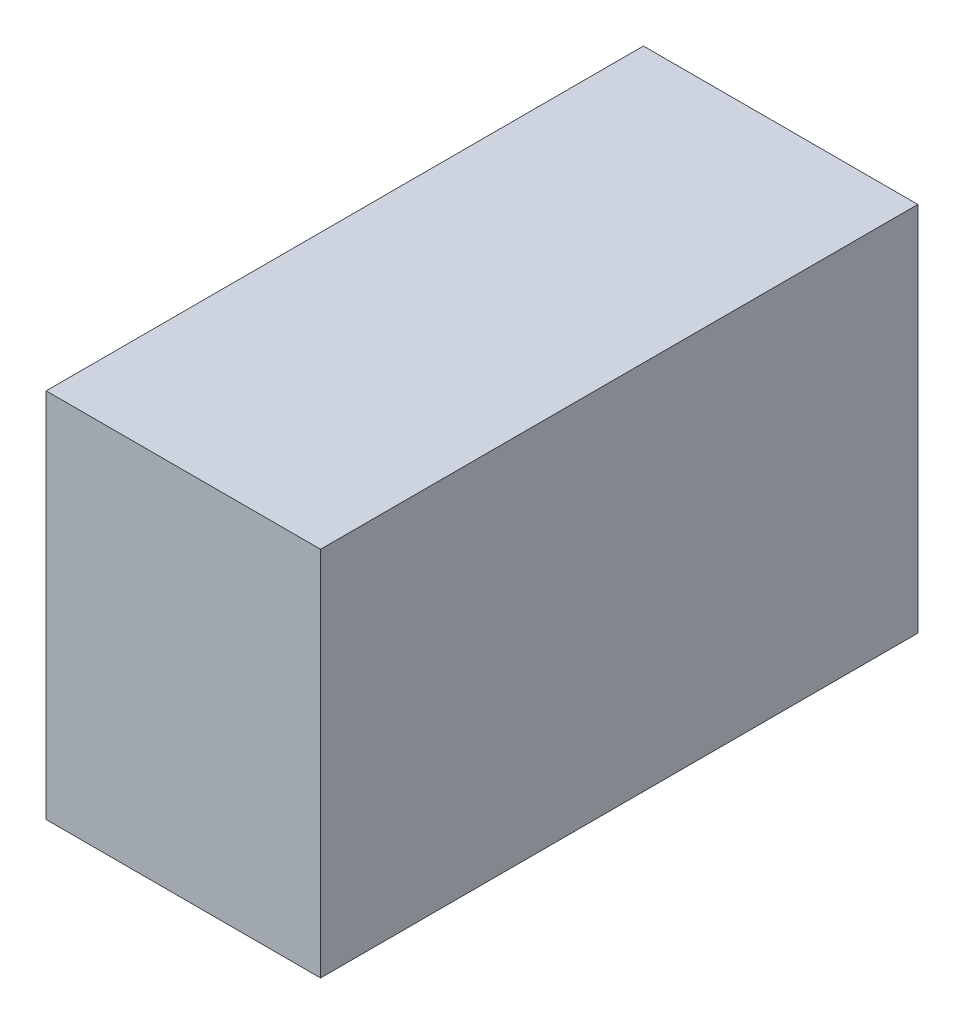
from build123d import *

# Parameters (mm, degrees)
SKETCH2_W           = 34
SKETCH2_H           = 74
BOSS_EXTRUDE1_DEPTH = 46


with BuildPart() as part:
    # Sketch2 → Boss-Extrude1 (new body)
    with BuildSketch(Plane(origin=(0, 0, 0), x_dir=(1, 0, 0), z_dir=(0, 1, 0))):
        with Locations((-84.75, 42.0875)):
            Rectangle(SKETCH2_W, SKETCH2_H)
    extrude(amount=BOSS_EXTRUDE1_DEPTH)


solid = part.part
